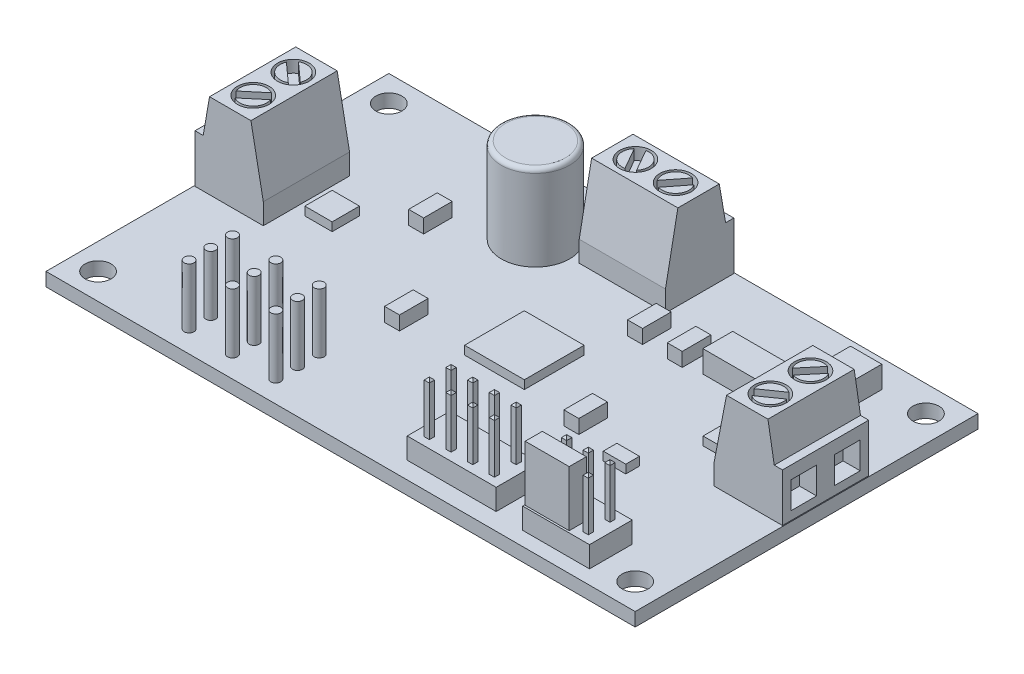
from build123d import *

# Parameters (mm, degrees)
SKETCH1_W            = 69
SKETCH1_H            = 40.15
SKETCH1_R            = 1.525
BASE_EXTRUDE_DEPTH   = 1.5748
SKETCH2_W            = 8
SKETCH2_H            = 10.1
SKETCH2_W_2          = 10.1
SKETCH2_H_2          = 8
BOSS_EXTRUDE1_DEPTH  = 9.94
CUT_EXTRUDE1_DEPTH   = 28.45
CUT_EXTRUDE2_DEPTH   = 41.5
SKETCH5_R            = 1.85
CUT_EXTRUDE3_DEPTH   = 2
BOSS_EXTRUDE4_REACH  = 13.515
SKETCH6_R            = 1.55
CUT_EXTRUDE4_DEPTH   = 1.2
CUT_EXTRUDE5_DEPTH   = 1.2
CUT_EXTRUDE6_DEPTH   = 1.2
SKETCH11_W           = 3
SKETCH11_H           = 3.14
CUT_EXTRUDE7_DEPTH   = 2
SKETCH12_W           = 3
SKETCH12_H           = 3.14
CUT_EXTRUDE8_DEPTH   = 2
SKETCH13_W           = 3
SKETCH13_H           = 3.14
CUT_EXTRUDE9_DEPTH   = 2
SKETCH14_R           = 4
BOSS_EXTRUDE5_DEPTH  = 10
FILLET1_R            = 0.5
SKETCH15_W           = 7.82
SKETCH15_H           = 5
SKETCH15_W_2         = 10.42
BOSS_EXTRUDE6_DEPTH  = 2.46
SKETCH16_W           = 0.61
SKETCH16_H           = 0.61
BOSS_EXTRUDE7_DEPTH  = 6
CHAMFER2_SIZE        = 0.25
SKETCH17_W           = 8.7
SKETCH17_H           = 9.54
BOSS_EXTRUDE8_DEPTH  = 4.35
SKETCH19_W           = 3.66
SKETCH19_H           = 4.2
SKETCH19_W_2         = 6.53
SKETCH19_H_2         = 3.5
BOSS_EXTRUDE9_DEPTH  = 2.58
SKETCH20_W           = 7
SKETCH20_H           = 7
BOSS_EXTRUDE10_DEPTH = 1
SKETCH21_R           = 0.575
BOSS_EXTRUDE11_DEPTH = 7
SKETCH22_R           = 0.575
BOSS_EXTRUDE12_DEPTH = 7
SKETCH23_R           = 0.575
BOSS_EXTRUDE13_DEPTH = 7
SKETCH24_W           = 3.2
SKETCH24_H           = 3.2
SKETCH24_W_2         = 2.64
SKETCH24_H_2         = 1.6
BOSS_EXTRUDE14_DEPTH = 1
SKETCH25_W           = 1.75
SKETCH25_H           = 3.35
BOSS_EXTRUDE15_DEPTH = 1.63
SKETCH26_W           = 5.15
SKETCH26_H           = 2.01
BOSS_EXTRUDE16_DEPTH = 6.5


with BuildPart() as part:
    # Sketch1 → Base-Extrude (new body)
    with BuildSketch(Plane(origin=(0, 0, 0), x_dir=(1, 0, 0), z_dir=(0, 1, 0))):
        with Locations((34.5, 20.075)):
            Rectangle(SKETCH1_W, SKETCH1_H)
        with Locations(Location((65.95, 37.1, 0), (0, 0, 270))):  # turned: the seam where the file's is
            Circle(SKETCH1_R, mode=Mode.SUBTRACT)
        with Locations(Location((3.05, 37.1, 0), (0, 0, 270))):  # turned: the seam where the file's is
            Circle(SKETCH1_R, mode=Mode.SUBTRACT)
        with Locations(Location((3.05, 3.05, 0), (0, 0, 270))):  # turned: the seam where the file's is
            Circle(SKETCH1_R, mode=Mode.SUBTRACT)
        with Locations(Location((65.95, 3.05, 0), (0, 0, 270))):  # turned: the seam where the file's is
            Circle(SKETCH1_R, mode=Mode.SUBTRACT)
    extrude(amount=-BASE_EXTRUDE_DEPTH)

    # Sketch2 → Boss-Extrude1 (add)
    with BuildSketch(Plane(origin=(0, 0, 0), x_dir=(-1, 0, 0), z_dir=(0, 1, 0))):
        with Locations((-64.9, -22.4)):
            Rectangle(SKETCH2_W, SKETCH2_H)
        with Locations((-4.1, -22.4)):
            Rectangle(SKETCH2_W, SKETCH2_H)
        with Locations((-35.45, -36.05)):
            Rectangle(SKETCH2_W_2, SKETCH2_H_2)
    extrude(amount=BOSS_EXTRUDE1_DEPTH)

    # Sketch3 → Cut-Extrude1 (cut, through all)
    with BuildSketch(Plane(origin=(0, 0, -27.45), x_dir=(-1, 0, 0), z_dir=(0, 0, -1))):
        Polygon((-8.1, 9.94), (-8.1, 2.44), (-6.65, 9.94), align=None)
        Polygon((-1.06, 5.64), (-1.8, 9.94), (-0.1, 9.94), (-0.1, 5.64), align=None)
        Polygon((-60.9, 9.94), (-60.9, 2.44), (-62.35, 9.94), align=None)
        Polygon((-68.9, 9.94), (-68.9, 5.64), (-67.94, 5.64), (-67.2, 9.94), align=None)
    extrude(amount=-CUT_EXTRUDE1_DEPTH, mode=Mode.SUBTRACT)

    # Sketch4 → Cut-Extrude2 (cut, through all)
    with BuildSketch(Plane(origin=(40.5, 0, 0), x_dir=(0, 0, -1), z_dir=(1, 0, 0))):
        Polygon((40.05, 9.94), (40.05, 5.64), (39.09, 5.64), (38.35, 9.94), align=None)
        Polygon((32.05, 9.94), (32.05, 2.44), (33.5, 9.94), align=None)
    extrude(amount=-CUT_EXTRUDE2_DEPTH, mode=Mode.SUBTRACT)

    # Sketch5 → Cut-Extrude3 (cut)
    with BuildSketch(Plane(origin=(0, 9.94, 0), x_dir=(-1, 0, 0), z_dir=(0, 1, 0))):
        with Locations(Location((-64.78, -20.05, 0), (0, 0, 90))):  # turned: the seam where the file's is
            Circle(SKETCH5_R)
        with Locations(Location((-64.78, -24.75, 0), (0, 0, 90))):  # turned: the seam where the file's is
            Circle(SKETCH5_R)
        with Locations(Location((-37.8, -35.93, 0), (0, 0, 90))):  # turned: the seam where the file's is
            Circle(SKETCH5_R)
        with Locations(Location((-33.1, -35.93, 0), (0, 0, 90))):  # turned: the seam where the file's is
            Circle(SKETCH5_R)
        with Locations(Location((-4.22, -24.75, 0), (0, 0, 90))):  # turned: the seam where the file's is
            Circle(SKETCH5_R)
        with Locations(Location((-4.22, -20.05, 0), (0, 0, 90))):  # turned: the seam where the file's is
            Circle(SKETCH5_R)
    extrude(amount=-CUT_EXTRUDE3_DEPTH, mode=Mode.SUBTRACT)

    # Sketch6 → Boss-Extrude4 (add, up to next)
    with BuildSketch(Plane(origin=(0, 9.94, 0), x_dir=(-1, 0, 0), z_dir=(0, 1, 0)), mode=Mode.PRIVATE) as boss_extrude4_sk1:
        with Locations(Location((-64.78, -20.05, 0), (0, 0, 90))):  # turned: the seam where the file's is
            Circle(SKETCH6_R)
    boss_extrude4_tool1 = extrude(boss_extrude4_sk1.sketch, amount=-BOSS_EXTRUDE4_REACH, mode=Mode.PRIVATE) - part.part
    add(boss_extrude4_tool1.solids().sort_by_distance((64.78, 9.94, -20.05))[0])
    # Sketch6 → Boss-Extrude4 (add, up to next)
    with BuildSketch(Plane(origin=(0, 9.94, 0), x_dir=(-1, 0, 0), z_dir=(0, 1, 0)), mode=Mode.PRIVATE) as boss_extrude4_sk2:
        with Locations(Location((-64.78, -24.75, 0), (0, 0, 90))):  # turned: the seam where the file's is
            Circle(SKETCH6_R)
    boss_extrude4_tool2 = extrude(boss_extrude4_sk2.sketch, amount=-BOSS_EXTRUDE4_REACH, mode=Mode.PRIVATE) - part.part
    add(boss_extrude4_tool2.solids().sort_by_distance((64.78, 9.94, -24.75))[0])
    # Sketch6 → Boss-Extrude4 (add, up to next)
    with BuildSketch(Plane(origin=(0, 9.94, 0), x_dir=(-1, 0, 0), z_dir=(0, 1, 0)), mode=Mode.PRIVATE) as boss_extrude4_sk3:
        with Locations(Location((-37.8, -35.93, 0), (0, 0, 90))):  # turned: the seam where the file's is
            Circle(SKETCH6_R)
    boss_extrude4_tool3 = extrude(boss_extrude4_sk3.sketch, amount=-BOSS_EXTRUDE4_REACH, mode=Mode.PRIVATE) - part.part
    add(boss_extrude4_tool3.solids().sort_by_distance((37.8, 9.94, -35.93))[0])
    # Sketch6 → Boss-Extrude4 (add, up to next)
    with BuildSketch(Plane(origin=(0, 9.94, 0), x_dir=(-1, 0, 0), z_dir=(0, 1, 0)), mode=Mode.PRIVATE) as boss_extrude4_sk4:
        with Locations(Location((-33.1, -35.93, 0), (0, 0, 90))):  # turned: the seam where the file's is
            Circle(SKETCH6_R)
    boss_extrude4_tool4 = extrude(boss_extrude4_sk4.sketch, amount=-BOSS_EXTRUDE4_REACH, mode=Mode.PRIVATE) - part.part
    add(boss_extrude4_tool4.solids().sort_by_distance((33.1, 9.94, -35.93))[0])
    # Sketch6 → Boss-Extrude4 (add, up to next)
    with BuildSketch(Plane(origin=(0, 9.94, 0), x_dir=(-1, 0, 0), z_dir=(0, 1, 0)), mode=Mode.PRIVATE) as boss_extrude4_sk5:
        with Locations(Location((-4.22, -24.75, 0), (0, 0, 90))):  # turned: the seam where the file's is
            Circle(SKETCH6_R)
    boss_extrude4_tool5 = extrude(boss_extrude4_sk5.sketch, amount=-BOSS_EXTRUDE4_REACH, mode=Mode.PRIVATE) - part.part
    add(boss_extrude4_tool5.solids().sort_by_distance((4.22, 9.94, -24.75))[0])
    # Sketch6 → Boss-Extrude4 (add, up to next)
    with BuildSketch(Plane(origin=(0, 9.94, 0), x_dir=(-1, 0, 0), z_dir=(0, 1, 0)), mode=Mode.PRIVATE) as boss_extrude4_sk6:
        with Locations(Location((-4.22, -20.05, 0), (0, 0, 90))):  # turned: the seam where the file's is
            Circle(SKETCH6_R)
    boss_extrude4_tool6 = extrude(boss_extrude4_sk6.sketch, amount=-BOSS_EXTRUDE4_REACH, mode=Mode.PRIVATE) - part.part
    add(boss_extrude4_tool6.solids().sort_by_distance((4.22, 9.94, -20.05))[0])

    # Sketch7 → Cut-Extrude4 (cut)
    with BuildSketch(Plane(origin=(0, 9.94, 0), x_dir=(-1, 0, 0), z_dir=(0, 1, 0))):
        with BuildLine():
            Line((-65.787149396, -21.365600894), (-63.199274168, -19.553551151))
            ThreePointArc((-63.199274168, -19.553551151), (-63.422787022, -19.099669242), (-63.772850604, -18.734399106))
            Line((-63.772850604, -18.734399106), (-66.360725832, -20.546448849))
            ThreePointArc((-66.360725832, -20.546448849), (-66.137212978, -21.000330758), (-65.787149396, -21.365600894))
        make_face()
        with BuildLine():
            Line((-65.392980718, -26.258383887), (-63.400974839, -23.884403723))
            ThreePointArc((-63.400974839, -23.884403723), (-63.733426623, -23.502742418), (-64.167019282, -23.241616113))
            Line((-64.167019282, -23.241616113), (-66.159025161, -25.615596277))
            ThreePointArc((-66.159025161, -25.615596277), (-65.826573377, -25.997257582), (-65.392980718, -26.258383887))
        make_face()
    extrude(amount=-CUT_EXTRUDE4_DEPTH, mode=Mode.SUBTRACT)

    # Sketch8 → Cut-Extrude5 (cut)
    with BuildSketch(Plane(origin=(0, 9.94, 0), x_dir=(-1, 0, 0), z_dir=(0, 1, 0))):
        with BuildLine():
            Line((-39.169868833, -36.871217527), (-37.218141921, -34.373120997))
            ThreePointArc((-37.218141921, -34.373120997), (-36.776735983, -34.620281784), (-36.430131167, -34.988782473))
            Line((-36.430131167, -34.988782473), (-38.381858079, -37.486879003))
            ThreePointArc((-38.381858079, -37.486879003), (-38.823264017, -37.239718216), (-39.169868833, -36.871217527))
        make_face()
        with BuildLine():
            Line((-32.739926533, -37.563021699), (-34.327561615, -34.794436152))
            ThreePointArc((-34.327561615, -34.794436152), (-33.931872807, -34.479344836), (-33.460073467, -34.296978301))
            Line((-33.460073467, -34.296978301), (-31.872438385, -37.065563848))
            ThreePointArc((-31.872438385, -37.065563848), (-32.268127193, -37.380655164), (-32.739926533, -37.563021699))
        make_face()
    extrude(amount=-CUT_EXTRUDE5_DEPTH, mode=Mode.SUBTRACT)

    # Sketch10 → Cut-Extrude6 (cut)
    with BuildSketch(Plane(origin=(0, 9.94, 0), x_dir=(-1, 0, 0), z_dir=(0, 1, 0))):
        with BuildLine():
            Line((-3.339895133, -26.215266346), (-5.769235473, -24.027878479))
            ThreePointArc((-5.769235473, -24.027878479), (-5.490232136, -23.606277847), (-5.100104867, -23.284733654))
            Line((-5.100104867, -23.284733654), (-2.670764527, -25.472121521))
            ThreePointArc((-2.670764527, -25.472121521), (-2.949767864, -25.893722153), (-3.339895133, -26.215266346))
        make_face()
        with BuildLine():
            Line((-3.325438406, -18.646670051), (-5.757349204, -20.687285505))
            ThreePointArc((-5.757349204, -20.687285505), (-5.494854327, -21.119729796), (-5.114561594, -21.453329949))
            Line((-5.114561594, -21.453329949), (-2.682650796, -19.412714495))
            ThreePointArc((-2.682650796, -19.412714495), (-2.945145673, -18.980270204), (-3.325438406, -18.646670051))
        make_face()
    extrude(amount=-CUT_EXTRUDE6_DEPTH, mode=Mode.SUBTRACT)

    # Sketch11 → Cut-Extrude7 (cut)
    with BuildSketch(Plane(origin=(0, 0, -40.05), x_dir=(-1, 0, 0), z_dir=(0, 0, -1))):
        with Locations((-38, 2.57)):
            Rectangle(SKETCH11_W, SKETCH11_H)
        with Locations((-32.9, 2.57)):
            Rectangle(SKETCH11_W, SKETCH11_H)
    extrude(amount=-CUT_EXTRUDE7_DEPTH, mode=Mode.SUBTRACT)

    # Sketch12 → Cut-Extrude8 (cut)
    with BuildSketch(Plane.ZY.offset(-0.1)):
        with Locations((-24.95, 2.57)):
            Rectangle(SKETCH12_W, SKETCH12_H)
        with Locations((-19.85, 2.57)):
            Rectangle(SKETCH12_W, SKETCH12_H)
    extrude(amount=-CUT_EXTRUDE8_DEPTH, mode=Mode.SUBTRACT)

    # Sketch13 → Cut-Extrude9 (cut)
    with BuildSketch(Plane(origin=(68.9, 0, 0), x_dir=(0, 0, -1), z_dir=(1, 0, 0))):
        with Locations((19.85, 2.57)):
            Rectangle(SKETCH13_W, SKETCH13_H)
        with Locations((24.95, 2.57)):
            Rectangle(SKETCH13_W, SKETCH13_H)
    extrude(amount=-CUT_EXTRUDE9_DEPTH, mode=Mode.SUBTRACT)

    # Sketch14 → Boss-Extrude5 (add)
    with BuildSketch(Plane(origin=(0, 0, 0), x_dir=(-1, 0, 0), z_dir=(0, 1, 0))):
        with Locations(Location((-25.4, -31.92, 0), (0, 0, 270))):  # turned: the seam where the file's is
            Circle(SKETCH14_R)
    extrude(amount=BOSS_EXTRUDE5_DEPTH)

    # Fillet1
    fillet1_edges = [part.edges().sort_by_distance(p)[0] for p in [
        (25.4, 10, -27.92),
    ]]
    fillet(fillet1_edges, radius=FILLET1_R)

    # Sketch15 → Boss-Extrude6 (add)
    with BuildSketch(Plane(origin=(0, 0, 0), x_dir=(-1, 0, 0), z_dir=(0, 1, 0))):
        with Locations((-58.09, -4.15)):
            Rectangle(SKETCH15_W, SKETCH15_H)
        with Locations((-45.51, -4.5)):
            Rectangle(SKETCH15_W_2, SKETCH15_H)
    extrude(amount=BOSS_EXTRUDE6_DEPTH)

    # Sketch16 → Boss-Extrude7 (add)
    with BuildSketch(Plane(origin=(0, 2.46, 0), x_dir=(-1, 0, 0), z_dir=(0, 1, 0))):
        with Locations((-60.63, -5.42)):
            Rectangle(SKETCH16_W, SKETCH16_H)
        with Locations((-60.63, -2.88)):
            Rectangle(SKETCH16_W, SKETCH16_H)
        with Locations((-58.09, -5.42)):
            Rectangle(SKETCH16_W, SKETCH16_H)
        with Locations((-58.09, -2.88)):
            Rectangle(SKETCH16_W, SKETCH16_H)
        with Locations((-55.55, -5.42)):
            Rectangle(SKETCH16_W, SKETCH16_H)
        with Locations((-55.55, -2.88)):
            Rectangle(SKETCH16_W, SKETCH16_H)
        with Locations((-49.295, -5.765)):
            Rectangle(SKETCH16_W, SKETCH16_H)
        with Locations((-49.295, -3.225)):
            Rectangle(SKETCH16_W, SKETCH16_H)
        with Locations((-46.755, -5.765)):
            Rectangle(SKETCH16_W, SKETCH16_H)
        with Locations((-46.755, -3.225)):
            Rectangle(SKETCH16_W, SKETCH16_H)
        with Locations((-44.215, -5.765)):
            Rectangle(SKETCH16_W, SKETCH16_H)
        with Locations((-44.215, -3.225)):
            Rectangle(SKETCH16_W, SKETCH16_H)
        with Locations((-41.675, -5.765)):
            Rectangle(SKETCH16_W, SKETCH16_H)
        with Locations((-41.675, -3.225)):
            Rectangle(SKETCH16_W, SKETCH16_H)
    extrude(amount=BOSS_EXTRUDE7_DEPTH)

    # Chamfer2
    chamfer2_edges = [part.edges().sort_by_distance(p)[0] for p in [
        (49.295, 8.46, -6.07),
        (48.99, 8.46, -5.765),
        (49.295, 8.46, -5.46),
        (49.6, 8.46, -5.765),
        (46.755, 8.46, -6.07),
        (46.45, 8.46, -5.765),
        (46.755, 8.46, -5.46),
        (47.06, 8.46, -5.765),
        (44.215, 8.46, -6.07),
        (43.91, 8.46, -5.765),
        (44.215, 8.46, -5.46),
        (44.52, 8.46, -5.765),
        (41.675, 8.46, -6.07),
        (41.37, 8.46, -5.765),
        (41.675, 8.46, -5.46),
        (41.98, 8.46, -5.765),
        (49.295, 8.46, -3.53),
        (48.99, 8.46, -3.225),
        (49.295, 8.46, -2.92),
        (49.6, 8.46, -3.225),
        (46.755, 8.46, -3.53),
        (46.45, 8.46, -3.225),
        (46.755, 8.46, -2.92),
        (47.06, 8.46, -3.225),
        (44.215, 8.46, -3.53),
        (43.91, 8.46, -3.225),
        (44.215, 8.46, -2.92),
        (44.52, 8.46, -3.225),
        (41.675, 8.46, -3.53),
        (41.37, 8.46, -3.225),
        (41.675, 8.46, -2.92),
        (41.98, 8.46, -3.225),
        (60.63, 8.46, -5.725),
        (60.325, 8.46, -5.42),
        (60.63, 8.46, -5.115),
        (60.935, 8.46, -5.42),
        (58.09, 8.46, -5.725),
        (57.785, 8.46, -5.42),
        (58.09, 8.46, -5.115),
        (58.395, 8.46, -5.42),
        (55.55, 8.46, -5.725),
        (55.245, 8.46, -5.42),
        (55.55, 8.46, -5.115),
        (55.855, 8.46, -5.42),
        (60.63, 8.46, -3.185),
        (60.325, 8.46, -2.88),
        (60.63, 8.46, -2.575),
        (60.935, 8.46, -2.88),
    ]]
    chamfer(chamfer2_edges, length=CHAMFER2_SIZE)

    # Sketch17 → Boss-Extrude8 (add)
    with BuildSketch(Plane.XZ.offset(1.5748)):
        with Locations((55.82, -15.7)):
            Rectangle(SKETCH17_W, SKETCH17_H)
        with Locations((55.82, -28.76)):
            Rectangle(SKETCH17_W, SKETCH17_H)
        with Locations((12.01, -15.7)):
            Rectangle(SKETCH17_W, SKETCH17_H)
        with Locations((12.01, -28.76)):
            Rectangle(SKETCH17_W, SKETCH17_H)
    extrude(amount=BOSS_EXTRUDE8_DEPTH)

    # Sketch19 → Boss-Extrude9 (add)
    with BuildSketch(Plane(origin=(0, 0, 0), x_dir=(-1, 0, 0), z_dir=(0, 1, 0))):
        with Locations((-59.1, -34.85)):
            Rectangle(SKETCH19_W, SKETCH19_H)
        with Locations((-52.135, -29.8)):
            Rectangle(SKETCH19_W_2, SKETCH19_H_2)
    extrude(amount=BOSS_EXTRUDE9_DEPTH)

    # Sketch20 → Boss-Extrude10 (add)
    with BuildSketch(Plane(origin=(0, 0, 0), x_dir=(-1, 0, 0), z_dir=(0, 1, 0))):
        with Locations((-36.5, -19.52)):
            Rectangle(SKETCH20_W, SKETCH20_H)
    extrude(amount=BOSS_EXTRUDE10_DEPTH)

    # Sketch21 → Boss-Extrude11 (add)
    with BuildSketch(Plane(origin=(0, 0, 0), x_dir=(-1, 0, 0), z_dir=(0, 1, 0))):
        with Locations(Location((-14.22, -2.54, 0), (0, 0, 270))):  # turned: the seam where the file's is
            Circle(SKETCH21_R)
        with Locations(Location((-19.3, -2.54, 0), (0, 0, 270))):  # turned: the seam where the file's is
            Circle(SKETCH21_R)
        with Locations(Location((-24.38, -2.54, 0), (0, 0, 270))):  # turned: the seam where the file's is
            Circle(SKETCH21_R)
    extrude(amount=BOSS_EXTRUDE11_DEPTH)

    # Sketch22 → Boss-Extrude12 (add)
    with BuildSketch(Plane(origin=(0, 0, 0), x_dir=(-1, 0, 0), z_dir=(0, 1, 0))):
        with Locations(Location((-14.22, -5.08, 0), (0, 0, 270))):  # turned: the seam where the file's is
            Circle(SKETCH22_R)
        with Locations(Location((-19.3, -5.08, 0), (0, 0, 270))):  # turned: the seam where the file's is
            Circle(SKETCH22_R)
        with Locations(Location((-24.38, -5.08, 0), (0, 0, 270))):  # turned: the seam where the file's is
            Circle(SKETCH22_R)
    extrude(amount=BOSS_EXTRUDE12_DEPTH)

    # Sketch23 → Boss-Extrude13 (add)
    with BuildSketch(Plane(origin=(0, 0, 0), x_dir=(-1, 0, 0), z_dir=(0, 1, 0))):
        with Locations(Location((-24.38, -7.62, 0), (0, 0, 270))):  # turned: the seam where the file's is
            Circle(SKETCH23_R)
        with Locations(Location((-19.3, -7.62, 0), (0, 0, 270))):  # turned: the seam where the file's is
            Circle(SKETCH23_R)
        with Locations(Location((-14.22, -7.62, 0), (0, 0, 270))):  # turned: the seam where the file's is
            Circle(SKETCH23_R)
    extrude(amount=BOSS_EXTRUDE13_DEPTH)

    # Sketch24 → Boss-Extrude14 (add)
    with BuildSketch(Plane(origin=(0, 0, 0), x_dir=(-1, 0, 0), z_dir=(0, 1, 0))):
        with Locations((-57.77, -22.38)):
            Rectangle(SKETCH24_W, SKETCH24_H)
        with Locations((-11.13, -22.38)):
            Rectangle(SKETCH24_W, SKETCH24_H)
        with Locations((-53.18, -14.2)):
            Rectangle(SKETCH24_W_2, SKETCH24_H_2)
    extrude(amount=BOSS_EXTRUDE14_DEPTH)

    # Sketch25 → Boss-Extrude15 (add)
    with BuildSketch(Plane(origin=(0, 0, 0), x_dir=(-1, 0, 0), z_dir=(0, 1, 0))):
        with Locations((-46.125, -29.185)):
            Rectangle(SKETCH25_W, SKETCH25_H)
        with Locations((-41.475, -29.185)):
            Rectangle(SKETCH25_W, SKETCH25_H)
        with Locations((-46.875, -16.325)):
            Rectangle(SKETCH25_W, SKETCH25_H)
        with Locations((-25.875, -16.325)):
            Rectangle(SKETCH25_W, SKETCH25_H)
        with Locations((-17.445, -27.575)):
            Rectangle(SKETCH25_W, SKETCH25_H)
    extrude(amount=BOSS_EXTRUDE15_DEPTH)

    # Sketch26 → Boss-Extrude16 (add)
    with BuildSketch(Plane(origin=(0, 2.46, 0), x_dir=(-1, 0, 0), z_dir=(0, 1, 0))):
        with Locations((-56.82, -2.88)):
            Rectangle(SKETCH26_W, SKETCH26_H)
    extrude(amount=BOSS_EXTRUDE16_DEPTH)


solid = part.part
